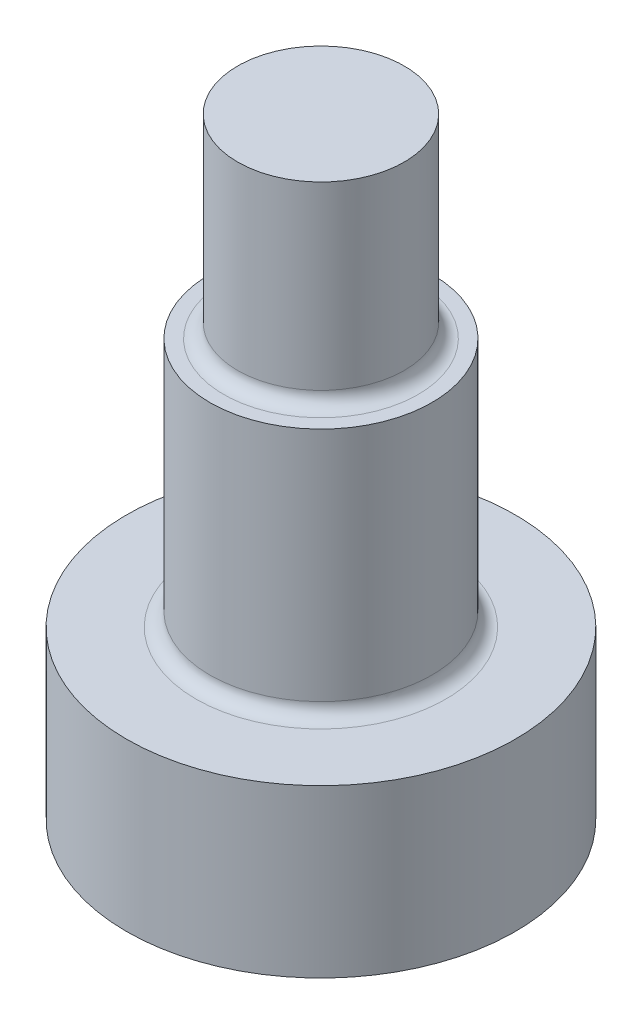
from build123d import *

# Parameters (mm, degrees)
CUT_EXTRUDE1_DEPTH = 2
FILLET1_R          = 0.5
FILLET2_R          = 0.5


with BuildPart() as part:
    # Sketch1 → Revolve1 (revolve)
    with BuildSketch(Plane.XY):
        Polygon((0, 0), (7, 0), (7, 6), (4, 6), (4, 15), (3, 15), (3, 22), (0, 22), align=None)
    revolve(axis=Axis((0, 22, 0), (0, -1, 0)))

    # Sketch2 → Cut-Extrude1 (cut)
    with BuildSketch(Plane.XZ):
        Polygon((0, -4.618802154), (4, -2.309401077), (4, 2.309401077), (0, 4.618802154), (-4, 2.309401077), (-4, -2.309401077), align=None)
    extrude(amount=-CUT_EXTRUDE1_DEPTH, mode=Mode.SUBTRACT)

    # Fillet1
    fillet1_edges = [part.edges().sort_by_distance(p)[0] for p in [
        (-4, 6, 0),
    ]]
    fillet(fillet1_edges, radius=FILLET1_R)

    # Fillet2
    fillet2_edges = [part.edges().sort_by_distance(p)[0] for p in [
        (-3, 15, 0),
    ]]
    fillet(fillet2_edges, radius=FILLET2_R)


solid = part.part
